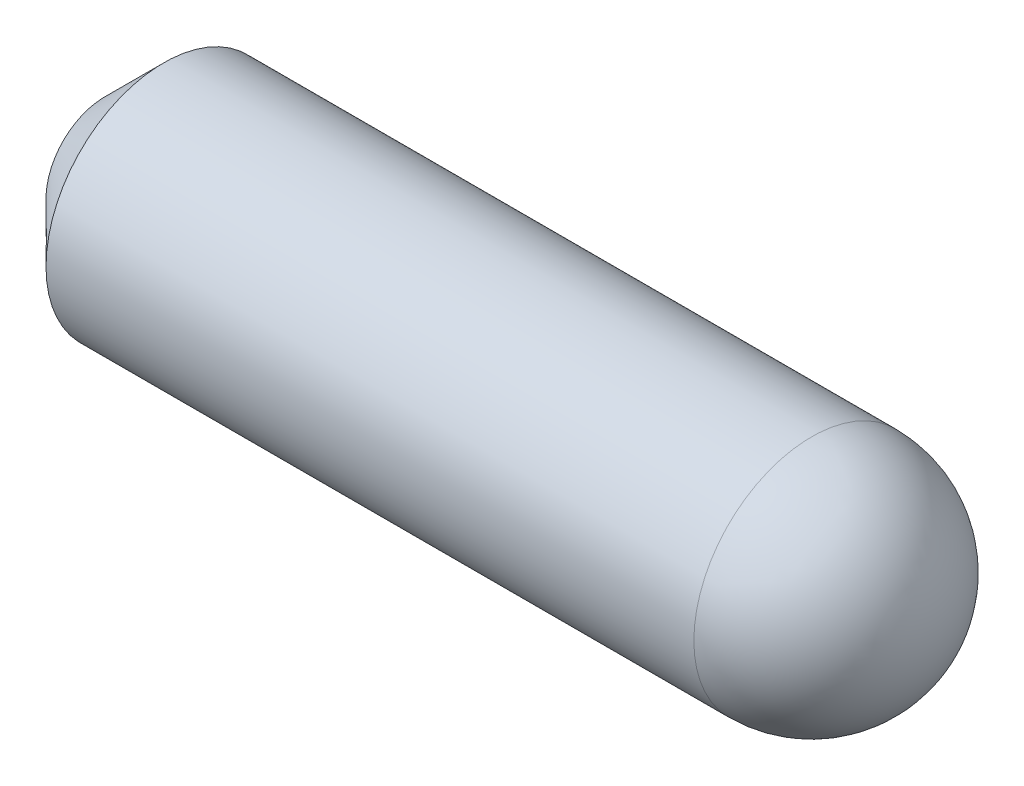
from build123d import *

# Parameters (mm, degrees)
SKETCH1_W     = 14
SKETCH1_H     = 2
CHAMFER1_SIZE = 1
FILLET1_R     = 2


with BuildPart() as part:
    # Sketch1 → Revolve1 (revolve)
    with BuildSketch(Plane.XY):
        with Locations((7, 1)):
            Rectangle(SKETCH1_W, SKETCH1_H)
    revolve(axis=Axis((-4.801500481, 0, 0), (1, 0, 0)))

    # Chamfer1
    chamfer1_edges = [part.edges().sort_by_distance(p)[0] for p in [
        (0, -2, 0),
    ]]
    chamfer(chamfer1_edges, length=CHAMFER1_SIZE)

    # Fillet1
    fillet1_edges = [part.edges().sort_by_distance(p)[0] for p in [
        (14, -2, 0),
    ]]
    fillet(fillet1_edges, radius=FILLET1_R)


solid = part.part
